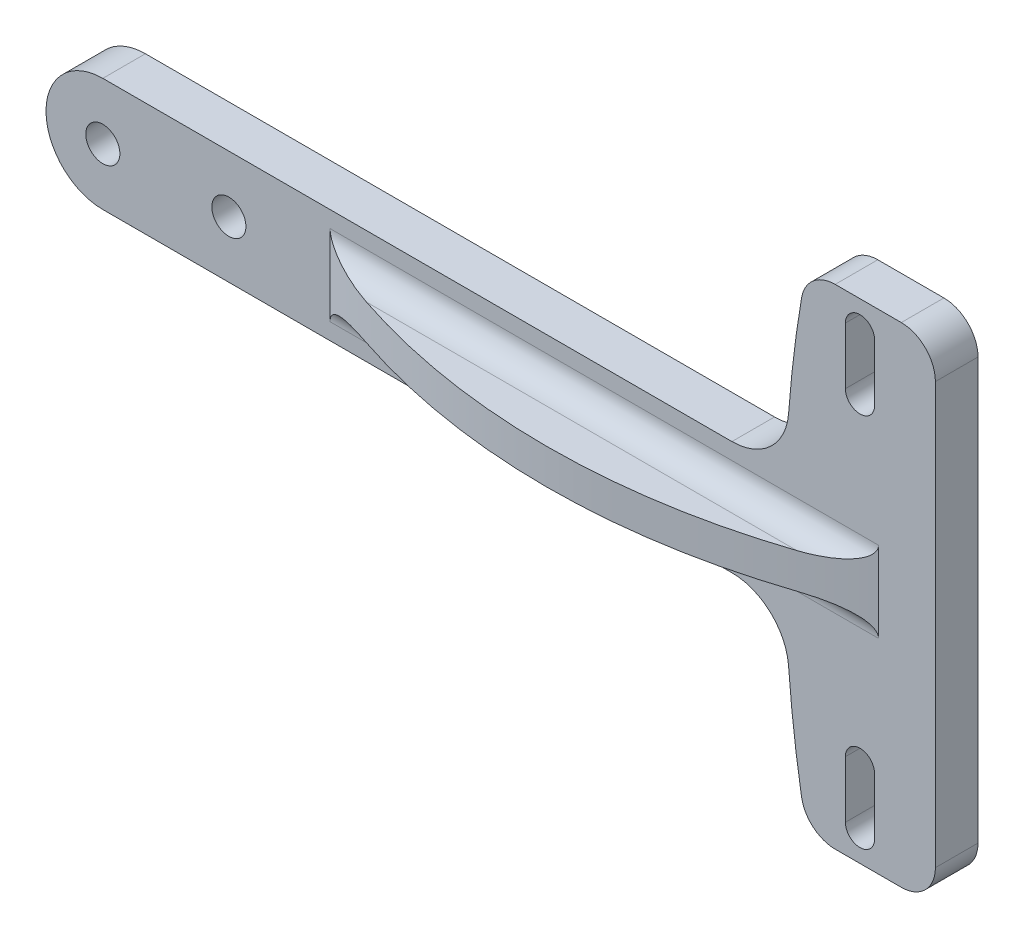
from build123d import *

# Parameters (mm, degrees)
SKETCH1_R           = 1.905
BOSS_EXTRUDE1_DEPTH = 4.7625
BOSS_EXTRUDE2_DEPTH = 1.9685
FILLET1_R           = 2.54


with BuildPart() as part:
    # Sketch1 → Boss-Extrude1 (new body)
    with BuildSketch(Plane.XY):
        with BuildLine():
            Line((-71.045544716, 27.335394647), (-63.656604316, 27.335394647))
            ThreePointArc((-63.656604316, 27.335394647), (-60.962527479, 26.219471483), (-59.846604316, 23.525394647))
            Line((-59.846604316, 23.525394647), (-59.846604316, 0))
            Line((-59.846604316, 0), (-59.846604316, -23.525394647))
            ThreePointArc((-59.846604316, -23.525394647), (-60.962527479, -26.219471483), (-63.656604316, -27.335394647))
            Line((-63.656604316, -27.335394647), (-71.045544716, -27.335394647))
            ThreePointArc((-71.045544716, -27.335394647), (-73.499934786, -26.439510188), (-74.800072929, -24.173173852))
            add(Edge.make_bspline(
                [(-76.255398054, -12.219815998), (-75.950115276, -16.245345964), (-75.476568023, -20.252208344), (-74.800072929, -24.173173852)],
                knots=[0.13080804, 0.13080804, 0.13080804, 0.13080804, 0.259951787, 0.259951787, 0.259951787, 0.259951787], degree=3))
            ThreePointArc((-76.255398054, -12.219815998), (-78.270195904, -8.04319485), (-82.587216381, -6.35))
            Line((-82.587216381, -6.35), (-152.901202739, -6.35))
            ThreePointArc((-152.901202739, -6.35), (-159.251202739, 0), (-152.901202739, 6.35))
            Line((-152.901202739, 6.35), (-82.587216381, 6.35))
            ThreePointArc((-82.587216381, 6.35), (-78.270195904, 8.04319485), (-76.255398054, 12.219815998))
            add(Edge.make_bspline(
                [(-74.800072929, 24.173173852), (-75.476568023, 20.252208344), (-75.950115276, 16.245345964), (-76.255398054, 12.219815998)],
                knots=[0.740048213, 0.740048213, 0.740048213, 0.740048213, 0.86919196, 0.86919196, 0.86919196, 0.86919196], degree=3))
            ThreePointArc((-74.800072929, 24.173173852), (-73.499934786, 26.439510188), (-71.045544716, 27.335394647))
        make_face()
        with Locations((-152.901202739, 0)):
            Circle(SKETCH1_R, mode=Mode.SUBTRACT)
        with Locations((-138.811822739, 0)):
            Circle(SKETCH1_R, mode=Mode.SUBTRACT)
        with Locations((-124.722442739, 0)):
            Circle(SKETCH1_R, mode=Mode.SUBTRACT)
        with Locations((-110.633062739, 0)):
            Circle(SKETCH1_R, mode=Mode.SUBTRACT)
        with Locations((-96.543682739, 0)):
            Circle(SKETCH1_R, mode=Mode.SUBTRACT)
        with Locations((-82.454302739, 0)):
            Circle(SKETCH1_R, mode=Mode.SUBTRACT)
        with BuildLine():
            Line((-69.905853527, -24.160394647), (-69.905853527, -17.810394647))
            ThreePointArc((-69.905853527, -17.810394647), (-68.273903527, -16.178444647), (-66.641953527, -17.810394647))
            Line((-66.641953527, -17.810394647), (-66.641953527, -24.160394647))
            ThreePointArc((-66.641953527, -24.160394647), (-68.273903527, -25.792344647), (-69.905853527, -24.160394647))
        make_face(mode=Mode.SUBTRACT)
        with BuildLine():
            Line((-69.905853527, 24.160394647), (-69.905853527, 17.810394647))
            ThreePointArc((-69.905853527, 17.810394647), (-68.273903527, 16.178444647), (-66.641953527, 17.810394647))
            Line((-66.641953527, 17.810394647), (-66.641953527, 24.160394647))
            ThreePointArc((-66.641953527, 24.160394647), (-68.273903527, 25.792344647), (-69.905853527, 24.160394647))
        make_face(mode=Mode.SUBTRACT)
    extrude(amount=BOSS_EXTRUDE1_DEPTH)

    # Sketch2 → Boss-Extrude2 (add, symmetric)
    with BuildSketch(Plane(origin=(0, 0, 0), x_dir=(1, 0, 0), z_dir=(0, 1, 0))):
        with BuildLine():
            Line((-66.196604316, -4.7625), (-127.501202739, -4.7625))
            ThreePointArc((-127.501202739, -4.7625), (-96.848903527, -11.199497248), (-66.196604316, -4.7625))
        make_face()
    extrude(amount=BOSS_EXTRUDE2_DEPTH, both=True)

    # Fillet1
    fillet1_edges = [part.edges().sort_by_distance(p)[0] for p in [
        (-96.848903527, -1.9685, 4.7625),
        (-96.848903527, 1.9685, 4.7625),
    ]]
    fillet(fillet1_edges, radius=FILLET1_R)


solid = part.part
